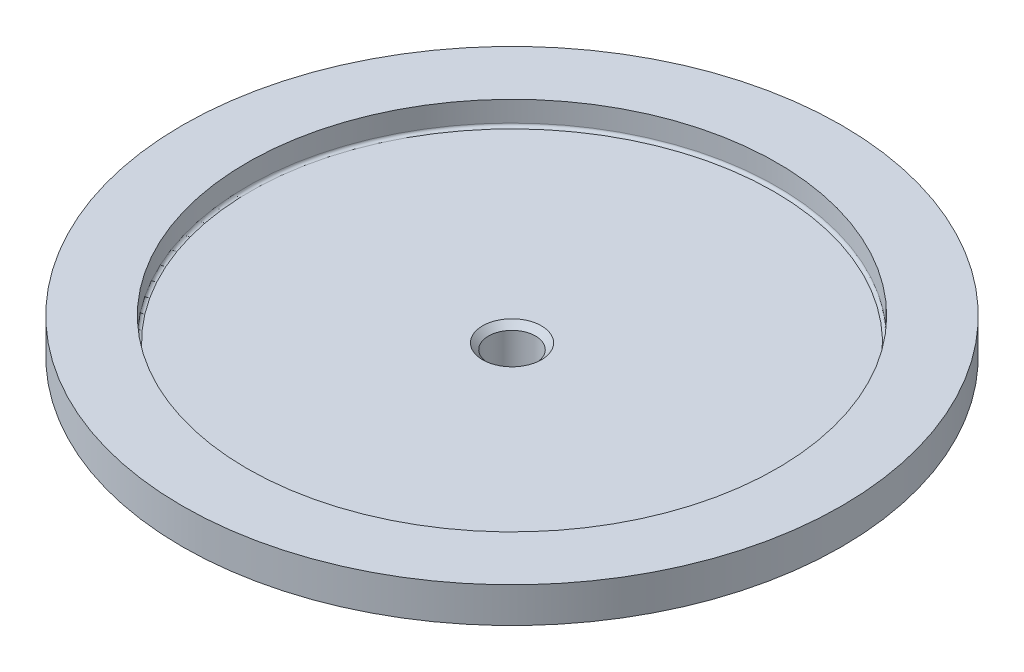
from build123d import *

# Parameters (mm, degrees)
SKETCH1_R          = 56
EXTRUDE1_DEPTH     = 7.5
SKETCH2_R          = 10
EXTRUDE5_DEPTH     = 35
SKETCH5_R          = 45
EXTRUDE6_DEPTH     = 4
SKETCH6_R          = 4
EXTRUDE7_DEPTH     = 39.5
CHAMFER3_SIZE      = 1
EXTRUDE8_DEPTH     = 67
EXTRUDE10_DEPTH    = 67
SKETCH10_W         = 20
SKETCH10_H         = 12.483117272
EXTRUDE11_DEPTH    = 67
SKETCH11_R         = 7.5
EXTRUDE12_DEPTH    = 1.5
SKETCH12_R         = 10
EXTRUDE13_DEPTH    = 5
SKETCH13_R         = 7.5
EXTRUDE15_DEPTH    = 3
CHAMFER4_SIZE      = 1.5
CHAMFER6_SIZE      = 1.5
CHAMFER7_SIZE      = 1.5
SKETCH16_R         = 4
EXTRUDE16_DEPTH    = 10.5
SKETCH17_OUTSIDE_W = 146.672
SKETCH17_OUTSIDE_H = 146.672
SKETCH17_OUTSIDE_R = 51
EXTRUDE17_DEPTH    = 1.5
FILLET7_R          = 0.5


with BuildPart() as part:
    # Sketch1 → Extrude1 (new body)
    with BuildSketch(Plane(origin=(0, 0, 0), x_dir=(1, 0, 0), z_dir=(0, 1, 0))):
        with Locations(Location((0, 0, 0), (0, 0, 270))):  # turned: the seam where the file's is
            Circle(SKETCH1_R)
    extrude(amount=EXTRUDE1_DEPTH)

    # Sketch2 → Extrude5 (add)
    with BuildSketch(Plane.XZ):
        with Locations(Location((0, 0, 0), (0, 0, 90))):  # turned: the seam where the file's is
            Circle(SKETCH2_R)
    extrude(amount=EXTRUDE5_DEPTH)

    # Sketch5 → Extrude6 (cut)
    with BuildSketch(Plane(origin=(0, 7.5, 0), x_dir=(1, 0, 0), z_dir=(0, 1, 0))):
        with Locations(Location((0, 0, 0), (0, 0, 270))):  # turned: the seam where the file's is
            Circle(SKETCH5_R)
    extrude(amount=-EXTRUDE6_DEPTH, mode=Mode.SUBTRACT)

    # Sketch6 → Extrude7 (cut, through all)
    with BuildSketch(Plane(origin=(0, 3.5, 0), x_dir=(1, 0, 0), z_dir=(0, 1, 0))):
        with Locations(Location((0, 0, 0), (0, 0, 270))):  # turned: the seam where the file's is
            Circle(SKETCH6_R)
    extrude(amount=-EXTRUDE7_DEPTH, mode=Mode.SUBTRACT)

    # Chamfer3
    chamfer3_edges = [part.edges().sort_by_distance(p)[0] for p in [
        (0, 3.5, -4),
    ]]
    chamfer(chamfer3_edges, length=CHAMFER3_SIZE)

    # Sketch7 → Extrude8 (cut, through all)
    with BuildSketch(Plane.XY.offset(10)):
        Polygon((-10, -23), (-8.939339828, -23), (-8.939339828, -24.689339828), (-10, -25.75), align=None)
    extrude8 = extrude(amount=-EXTRUDE8_DEPTH, mode=Mode.SUBTRACT)

    # Mirror2: Extrude8 across plane
    add(extrude8.mirror(Plane(origin=(0, 0, 0), x_dir=(0, 0, 1), z_dir=(1, 0, 0))), mode=Mode.SUBTRACT)

    # Sketch9 → Extrude10 (cut, through all)
    with BuildSketch(Plane.XY.offset(10)):
        Polygon((-10, -35), (-10, -32.25), (-9.116116524, -33.133883476), (-9.116116524, -34.133883476), (-8.25, -35), align=None)
    extrude10 = extrude(amount=-EXTRUDE10_DEPTH, mode=Mode.SUBTRACT)

    # Mirror3: Extrude10 across plane
    add(extrude10.mirror(Plane(origin=(0, 0, 0), x_dir=(0, 0, 1), z_dir=(1, 0, 0))), mode=Mode.SUBTRACT)

    # Sketch10 → Extrude11 (cut, through all)
    with BuildSketch(Plane.XY.offset(10)):
        with Locations((0, -29.241558636)):
            Rectangle(SKETCH10_W, SKETCH10_H)
    extrude(amount=-EXTRUDE11_DEPTH, mode=Mode.SUBTRACT)

    # Sketch11 → Extrude12 (add)
    with BuildSketch(Plane.XZ.offset(23)):
        with Locations(Location((0, 0, 0), (0, 0, 270))):  # turned: the seam where the file's is
            Circle(SKETCH11_R)
    extrude(amount=EXTRUDE12_DEPTH)

    # Sketch12 → Extrude13 (add)
    with BuildSketch(Plane.XZ.offset(24.5)):
        with Locations(Location((0, 0, 0), (0, 0, 90))):  # turned: the seam where the file's is
            Circle(SKETCH12_R)
    extrude(amount=EXTRUDE13_DEPTH)

    # Sketch13 → Extrude15 (add)
    with BuildSketch(Plane.XZ.offset(29.5)):
        with Locations(Location((0, 0, 0), (0, 0, 270))):  # turned: the seam where the file's is
            Circle(SKETCH13_R)
    extrude(amount=EXTRUDE15_DEPTH)

    # Chamfer4
    chamfer4_edges = [part.edges().sort_by_distance(p)[0] for p in [
        (0, -32.5, 7.5),
    ]]
    chamfer(chamfer4_edges, length=CHAMFER4_SIZE)

    # Chamfer6
    chamfer6_edges = [part.edges().sort_by_distance(p)[0] for p in [
        (0, -24.5, -10),
    ]]
    chamfer(chamfer6_edges, length=CHAMFER6_SIZE)

    # Chamfer7
    chamfer7_edges = [part.edges().sort_by_distance(p)[0] for p in [
        (0, -29.5, -10),
    ]]
    chamfer(chamfer7_edges, length=CHAMFER7_SIZE)

    # Sketch16 → Extrude16 (cut, through all)
    with BuildSketch(Plane(origin=(0, -23, 0), x_dir=(-1, 0, 0), z_dir=(0, 1, 0))):
        with Locations(Location((0, 0, 0), (0, 0, 90))):  # turned: the seam where the file's is
            Circle(SKETCH16_R)
    extrude(amount=-EXTRUDE16_DEPTH, mode=Mode.SUBTRACT)

    # Sketch17 outside → Extrude17 (cut)
    with BuildSketch(Plane.XZ):
        Rectangle(SKETCH17_OUTSIDE_W, SKETCH17_OUTSIDE_H)
        with Locations(Location((0, 0, 0), (0, 0, 270))):  # turned: the seam where the file's is
            Circle(SKETCH17_OUTSIDE_R, mode=Mode.SUBTRACT)
    extrude(amount=-EXTRUDE17_DEPTH, mode=Mode.SUBTRACT)

    # Fillet7
    fillet7_edges = [part.edges().sort_by_distance(p)[0] for p in [
        (0, 3.5, -45),
    ]]
    fillet(fillet7_edges, radius=FILLET7_R)


solid = part.part
